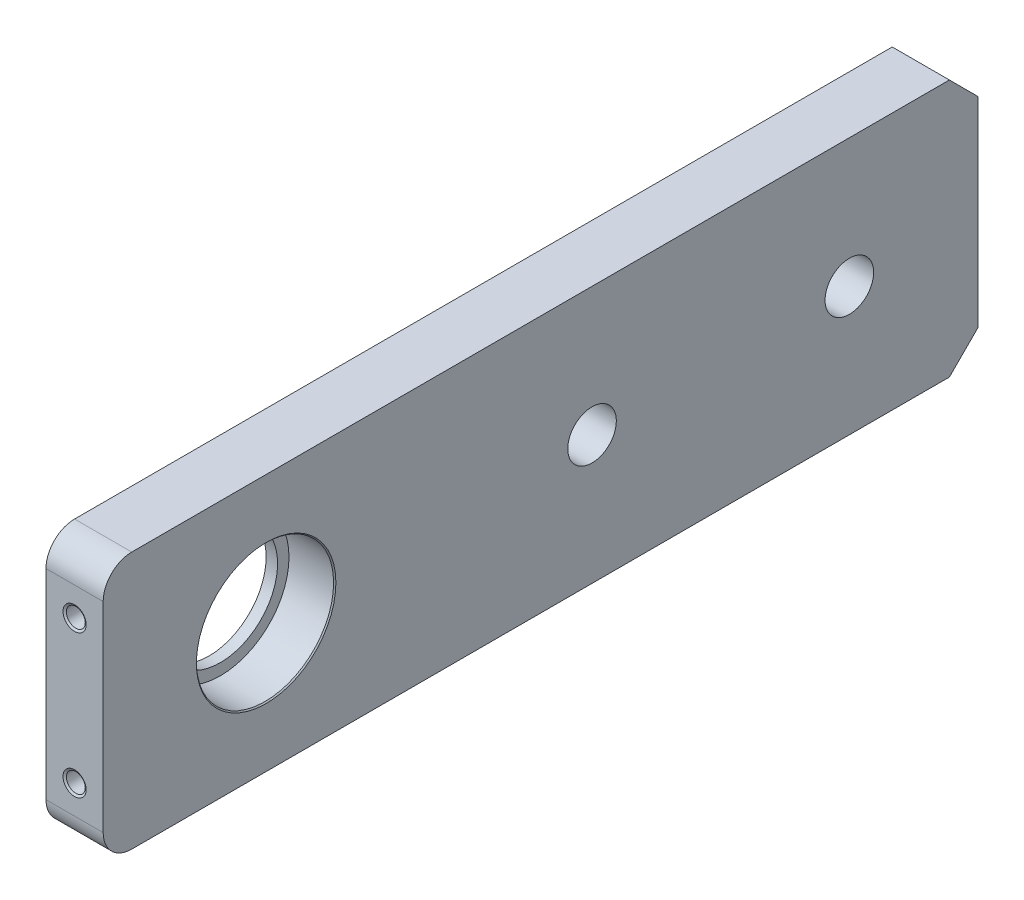
from build123d import *

# Parameters (mm, degrees)
SKETCH_1_W                   = 153
SKETCH_1_H                   = 45
SKETCH_1_R                   = 10
SKETCH_1_R_2                 = 4.25
EXTRUDE_1_DEPTH              = 5
SKETCH_6_R                   = 12
CUT_EXTRUDE_1009_DEPTH       = 8
CHAMFER_1_SIZE               = 5
FILLET_1_R                   = 5
CHAMFER_2_SIZE               = 0.2
HOLE_WIZARD_M4_1_D           = 3.3
HOLE_WIZARD_M4_1_DEPTH       = 15.5
HOLE_WIZARD_M4_1_CSINK_D     = 4.05
HOLE_WIZARD_M4_1_CSINK_ANGLE = 120


with BuildPart() as part:
    # 草图1 → 凸台-拉伸1 (new body, symmetric)
    with BuildSketch(Plane(origin=(0, 0, 0), x_dir=(0, 0, -1), z_dir=(1, 0, 0))):
        with Locations((76.5, -22.5)):
            Rectangle(SKETCH_1_W, SKETCH_1_H)
        with Locations((28.5, -22.5)):
            Circle(SKETCH_1_R, mode=Mode.SUBTRACT)
        with Locations((85.5, -22.5)):
            Circle(SKETCH_1_R_2, mode=Mode.SUBTRACT)
        with Locations((130.5, -22.5)):
            Circle(SKETCH_1_R_2, mode=Mode.SUBTRACT)
    extrude(amount=EXTRUDE_1_DEPTH, both=True)

    # 草图6 → Cut-Extrude 1009 (cut)
    with BuildSketch(Plane.ZY.offset(-5)):
        with Locations((-28.5, -22.5)):
            Circle(SKETCH_6_R)
    extrude(amount=CUT_EXTRUDE_1009_DEPTH, mode=Mode.SUBTRACT)

    # 倒角1
    chamfer_1_edges = [part.edges().sort_by_distance(p)[0] for p in [
        (0, 0, -153),
        (0, -45, -153),
    ]]
    chamfer(chamfer_1_edges, length=CHAMFER_1_SIZE)

    # 圆角1
    fillet_1_edges = [part.edges().sort_by_distance(p)[0] for p in [
        (0, 0, 0),
        (0, -45, 0),
    ]]
    fillet(fillet_1_edges, radius=FILLET_1_R)

    # 倒角2
    chamfer_2_edges = [part.edges().sort_by_distance(p)[0] for p in [
        (5, -22.5, -40.5),
    ]]
    chamfer(chamfer_2_edges, length=CHAMFER_2_SIZE)

    # M4 螺纹孔1
    with Locations(Plane.XY):
        with Locations((0, -10), (0, -35)):
            CounterSinkHole(HOLE_WIZARD_M4_1_D / 2, HOLE_WIZARD_M4_1_CSINK_D / 2, depth=HOLE_WIZARD_M4_1_DEPTH, counter_sink_angle=HOLE_WIZARD_M4_1_CSINK_ANGLE)


solid = part.part
